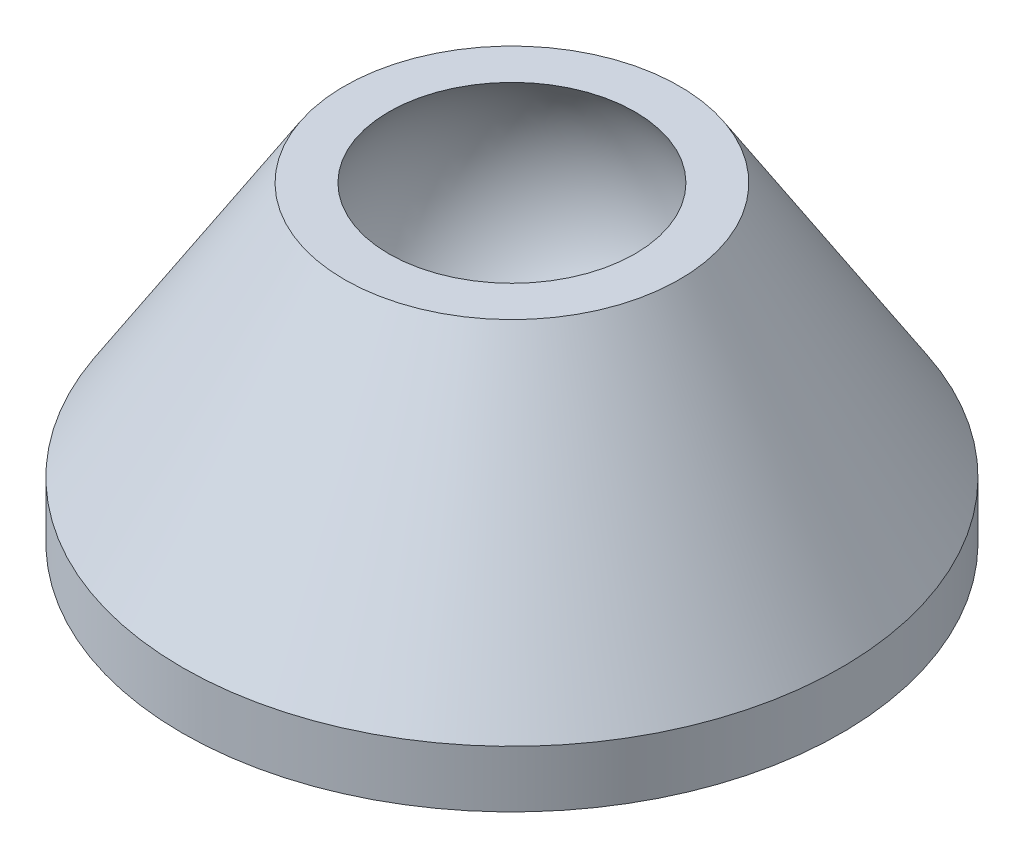
from build123d import *


with BuildPart() as part:
    # Sketch1 → Revolve1 (revolve)
    with BuildSketch(Plane.XY):
        with BuildLine():
            Line((12.7, -6.150685179), (6.455964927, 3.675363757))
            Line((6.455964927, 3.675363757), (4.742541645, 3.675363757))
            ThreePointArc((4.742541645, 3.675363757), (5.387586776, -2.640815921), (0, -6))
            Line((0, -6), (0, -9.059401987))
            Line((0, -9.059401987), (11.244226909, -9.059401987))
            ThreePointArc((11.244226909, -9.059401987), (11.5977803, -8.912955378), (11.744226909, -8.559401987))
            Line((11.744226909, -8.559401987), (11.744226909, -8.340026624))
            Line((11.744226909, -8.340026624), (12.7, -8.340026624))
            Line((12.7, -8.340026624), (12.7, -6.150685179))
        make_face()
    revolve(axis=Axis((0, 0, 0), (0, -1, 0)))


solid = part.part
